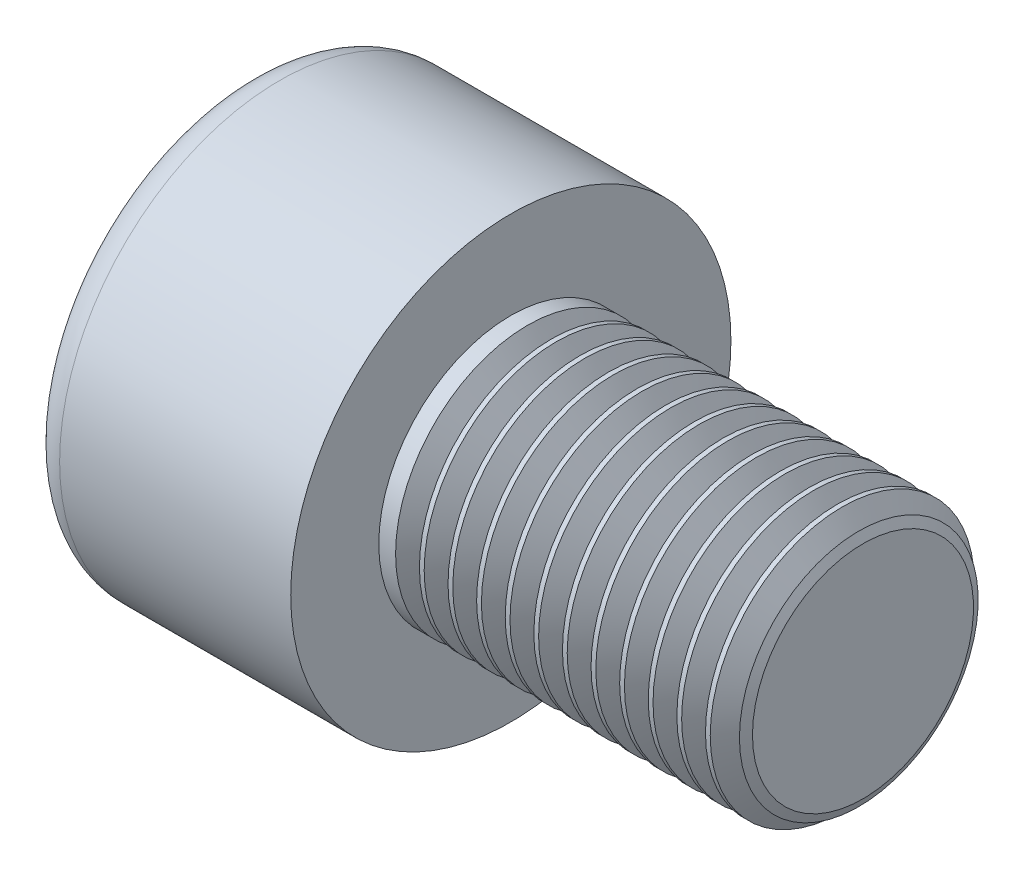
from build123d import *

# Parameters (mm, degrees)
SKETCH1_R           = 5
BASEHEAD_DEPTH      = 6
SKETCH2_R           = 3
BASEBODY_DEPTH      = 10
HEXAGONSOCKET_DEPTH = 3
TOPFILLET_R         = 0.75
CHAMFER1_SIZE       = 0.25
LPATTERN10_COUNT    = 15
LPATTERN10_PITCH    = 0.6498
SKETCH_1_W          = 12.577775012
SKETCH_1_H          = 7.589665947
CUT_EXTRUDE_1_DEPTH = 2


with BuildPart() as part:
    # Sketch1 → BaseHead (new body)
    with BuildSketch(Plane(origin=(0, 0, 0), x_dir=(0, 0, -1), z_dir=(1, 0, 0))):
        Circle(SKETCH1_R)
    extrude(amount=BASEHEAD_DEPTH)

    # Sketch2 → BaseBody (add)
    with BuildSketch(Plane(origin=(6, 0, 0), x_dir=(0, 0, -1), z_dir=(1, 0, 0))):
        Circle(SKETCH2_R)
    extrude(amount=BASEBODY_DEPTH)

    # Sketch3 → HexagonSocket (cut)
    with BuildSketch(Plane(origin=(0, 0, 0), x_dir=(0, 0, -1), z_dir=(1, 0, 0))):
        Polygon((2.886751346, 0), (1.443375673, 2.5), (-1.443375673, 2.5), (-2.886751346, 0), (-1.443375673, -2.5), (1.443375673, -2.5), align=None)
    extrude(amount=HEXAGONSOCKET_DEPTH, mode=Mode.SUBTRACT)

    # Sketch4 → Cut-Revolve1 (revolve, cut)
    with BuildSketch(Plane(origin=(-4.19613823, 0.75, 0), x_dir=(-1, 0, 0), z_dir=(0, 0, 1))):
        Polygon((-7.19613823, 3.25), (-8.639513903, 0.75), (-7.19613823, 0.75), align=None)
    revolve(axis=Axis((0.838992387, 0, 0), (-1, 0, 0)), mode=Mode.SUBTRACT)

    # TopFillet
    topfillet_edges = [part.edges().sort_by_distance(p)[0] for p in [
        (0, 0, 5),
    ]]
    fillet(topfillet_edges, radius=TOPFILLET_R)

    # Chamfer1
    chamfer1_edges = [part.edges().sort_by_distance(p)[0] for p in [
        (16, 0, 3),
    ]]
    chamfer(chamfer1_edges, length=CHAMFER1_SIZE)

    # Sketch5 → Cut-Revolve10 (revolve, cut)
    with BuildSketch(Plane.XY):
        Polygon((15.75, 2.531047244), (16.02075, 3), (16.02075, 3.5415), (15.47925, 3.5415), (15.47925, 3), align=None)
    cut_revolve10 = revolve(axis=Axis((0, 0, 0), (1, 0, 0)), mode=Mode.SUBTRACT)

    # LPattern10: Cut-Revolve10 ×15
    with Locations(*[(-i * LPATTERN10_PITCH, 0, 0) for i in range(1, LPATTERN10_COUNT)]):
        add(cut_revolve10, mode=Mode.SUBTRACT)

    # 草图1 → 切除-拉伸1 (cut)
    with BuildSketch(Plane(origin=(16, 0, 0), x_dir=(0, 0, -1), z_dir=(1, 0, 0))):
        with Locations((-0.655764338, 0.333257287)):
            Rectangle(SKETCH_1_W, SKETCH_1_H)
    extrude(amount=-CUT_EXTRUDE_1_DEPTH, mode=Mode.SUBTRACT)

    # 草图2 → 切除-旋转1 (revolve, cut)
    with BuildSketch(Plane.XY):
        Polygon((14, 2.510742744), (13.709985541, 3.124600146), (14, 3.124600146), align=None)
    revolve(axis=Axis((0, 0, 0), (1, 0, 0)), mode=Mode.SUBTRACT)


solid = part.part
